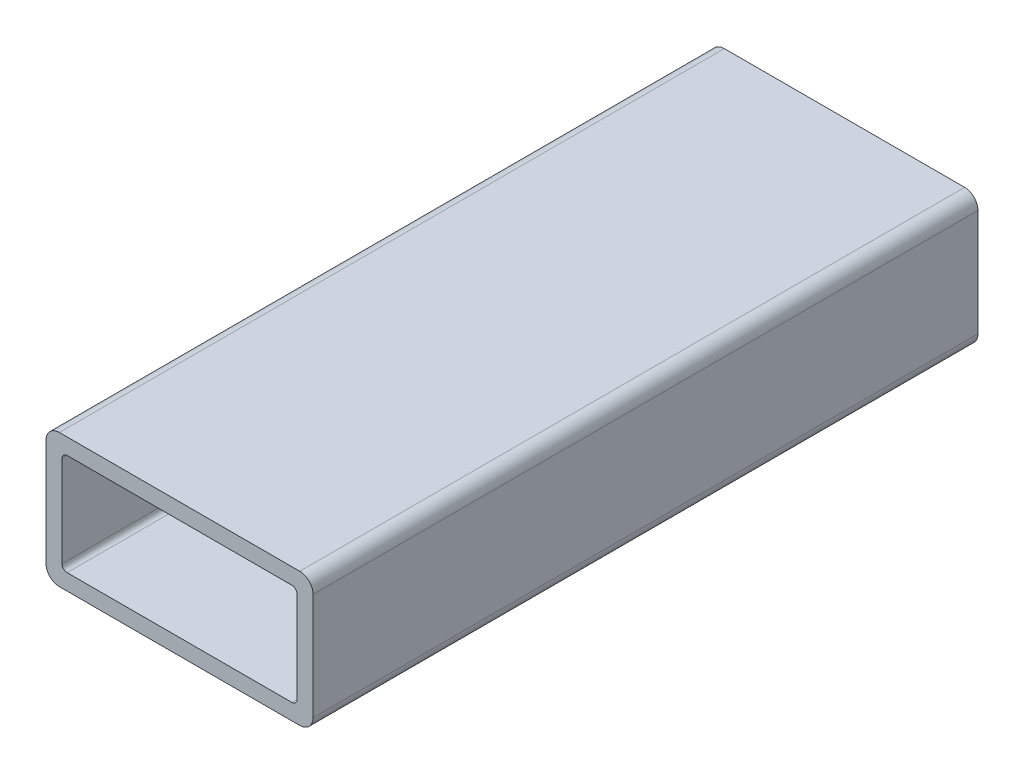
from build123d import *

# Parameters (mm, degrees)
BOSS_EXTRUDE1_DEPTH = 126.48184


with BuildPart() as part:
    # Sketch4 → Boss-Extrude1 (new body)
    with BuildSketch(Plane.XY):
        with BuildLine():
            Line((25.4, -10.16), (25.4, 10.16))
            ThreePointArc((25.4, 10.16), (24.656051224, 11.956051224), (22.86, 12.7))
            Line((22.86, 12.7), (-22.86, 12.7))
            ThreePointArc((-22.86, 12.7), (-24.656051224, 11.956051224), (-25.4, 10.16))
            Line((-25.4, 10.16), (-25.4, -10.16))
            ThreePointArc((-25.4, -10.16), (-24.656051224, -11.956051224), (-22.86, -12.7))
            Line((-22.86, -12.7), (22.86, -12.7))
            ThreePointArc((22.86, -12.7), (24.656051224, -11.956051224), (25.4, -10.16))
        make_face()
        with BuildLine():
            Line((22.352, 8.6868), (22.352, -8.6868))
            ThreePointArc((22.352, -8.6868), (22.069299465, -9.369299465), (21.3868, -9.652))
            Line((21.3868, -9.652), (-21.3868, -9.652))
            ThreePointArc((-21.3868, -9.652), (-22.069299465, -9.369299465), (-22.352, -8.6868))
            Line((-22.352, -8.6868), (-22.352, 8.6868))
            ThreePointArc((-22.352, 8.6868), (-22.069299465, 9.369299465), (-21.3868, 9.652))
            Line((-21.3868, 9.652), (21.3868, 9.652))
            ThreePointArc((21.3868, 9.652), (22.069299465, 9.369299465), (22.352, 8.6868))
        make_face(mode=Mode.SUBTRACT)
    extrude(amount=BOSS_EXTRUDE1_DEPTH)


solid = part.part
